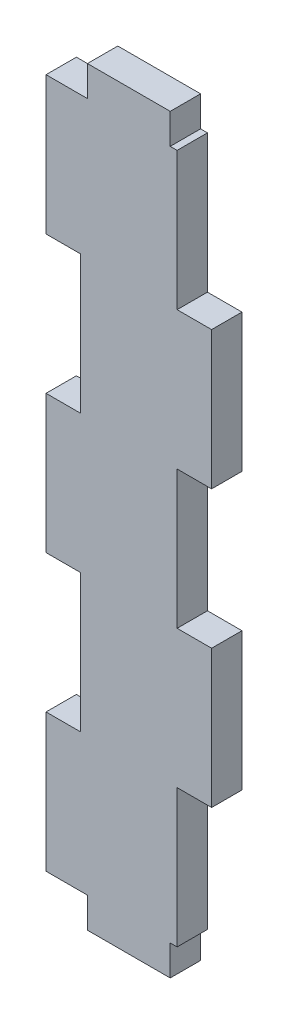
from build123d import *

# Parameters (mm, degrees)
EXTRUDE_1_DEPTH = 4.4


with BuildPart() as part:
    # 草图1 → 凸台-拉伸1 (new body)
    with BuildSketch(Plane.XY):
        Polygon((6, 50), (6, 54.4), (-6, 54.4), (-6, 50), (-7, 50), (-12, 50), (-12, 30), (-7, 30), (-7, 10), (-12, 10), (-12, -10), (-7, -10), (-7, -30), (-12, -30), (-12, -50), (-7, -50), (-6, -50), (-6, -54.4), (6, -54.4), (6, -50), (7, -50), (7, -30), (12, -30), (12, -10), (7, -10), (7, 10), (12, 10), (12, 30), (7, 30), (7, 50), align=None)
    extrude(amount=EXTRUDE_1_DEPTH)


solid = part.part
